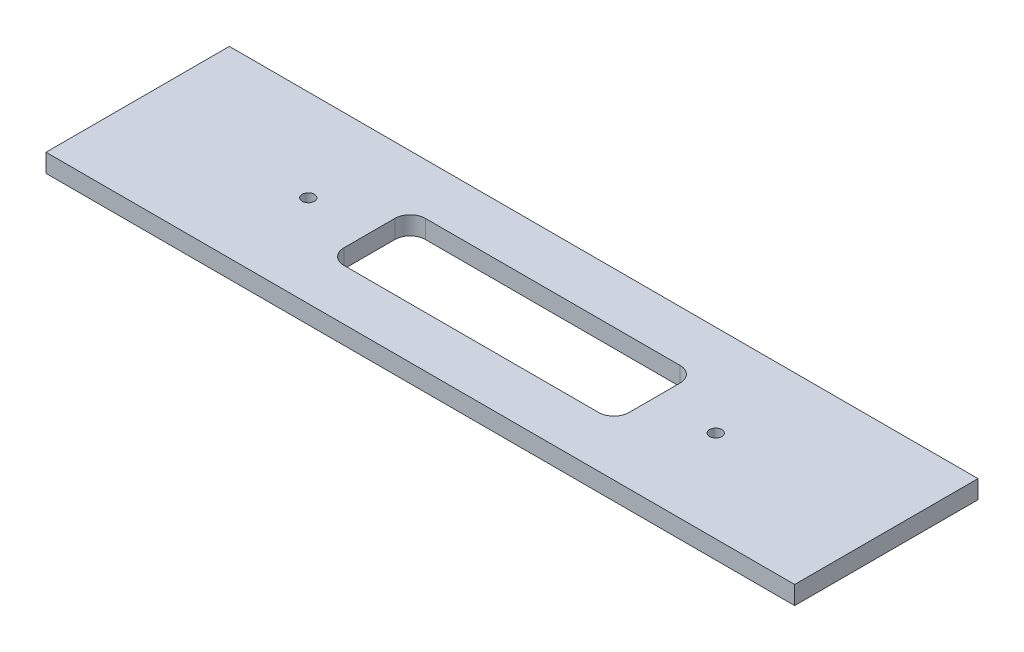
from build123d import *

# Parameters (mm, degrees)
SKETCH1_W           = 735
SKETCH1_H           = 180
BOSS_EXTRUDE1_DEPTH = 18
SKETCH2_R           = 6
CUT_EXTRUDE1_DEPTH  = 60


with BuildPart() as part:
    # Sketch1 → Boss-Extrude1 (new body)
    with BuildSketch(Plane(origin=(0, 0, 0), x_dir=(1, 0, 0), z_dir=(0, 1, 0))):
        Rectangle(SKETCH1_W, SKETCH1_H)
    extrude(amount=BOSS_EXTRUDE1_DEPTH)

    # Sketch2 → Cut-Extrude1 (cut)
    with BuildSketch(Plane(origin=(0, 18, 0), x_dir=(1, 0, 0), z_dir=(0, 1, 0))):
        with Locations((-200, 0)):
            Circle(SKETCH2_R)
        with Locations((200, 0)):
            Circle(SKETCH2_R)
        with BuildLine():
            Line((-125, -40), (125, -40))
            ThreePointArc((125, -40), (135.606601718, -35.606601718), (140, -25))
            Line((140, -25), (140, 25))
            ThreePointArc((140, 25), (135.606601718, 35.606601718), (125, 40))
            Line((125, 40), (-125, 40))
            ThreePointArc((-125, 40), (-135.606601718, 35.606601718), (-140, 25))
            Line((-140, 25), (-140, -25))
            ThreePointArc((-140, -25), (-135.606601718, -35.606601718), (-125, -40))
        make_face()
    extrude(amount=-CUT_EXTRUDE1_DEPTH, mode=Mode.SUBTRACT)


solid = part.part
